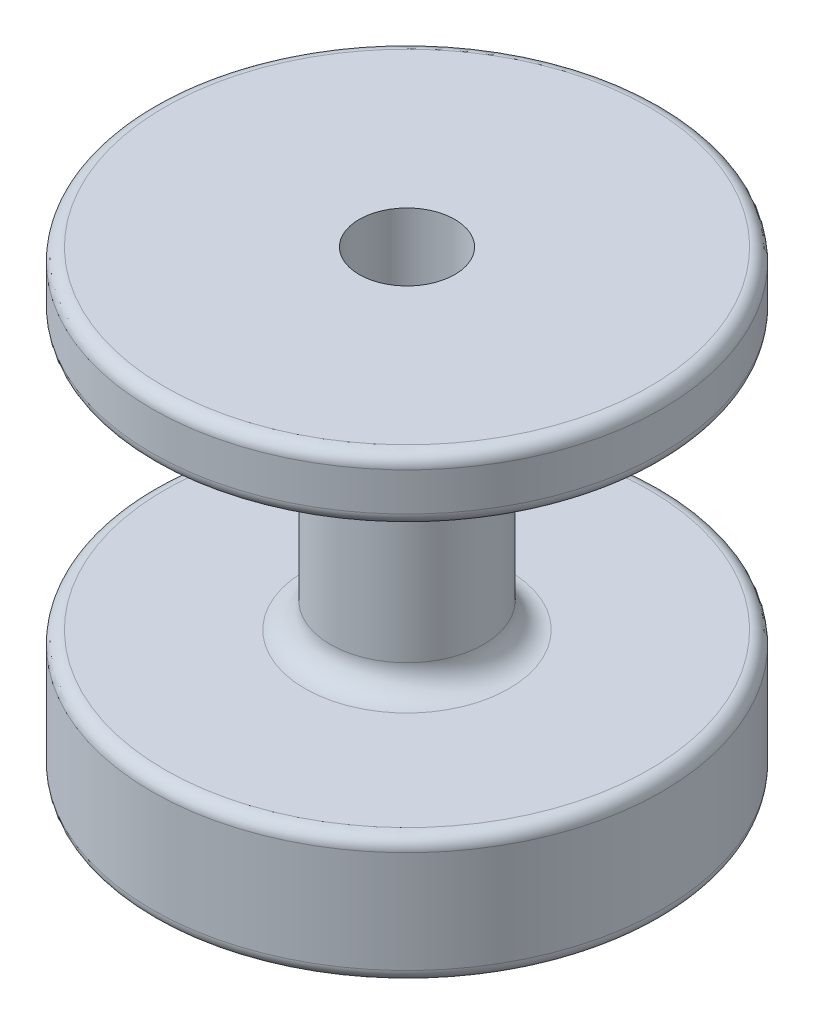
from build123d import *

# Parameters (mm, degrees)
SKETCH_1_R               = 20
EXTRUDE_1_DEPTH          = 36
CUT_EXTRUDE_START        = 10
SKETCH_2_R               = 20
SKETCH_2_R_2             = 6
CUT_EXTRUDE_1_DEPTH      = 21
SKETCH_4_R               = 2
CUT_EXTRUDE_3_DEPTH      = 47
CUT_EXTRUDE_3_DEPTH_BACK = 47
SKETCH_3_R               = 3.75
CUT_EXTRUDE_7_DEPTH      = 17
FILLET_1_R               = 2
FILLET_2_R               = 1


with BuildPart() as part:
    # 草图1 → 凸台-拉伸1 (new body)
    with BuildSketch(Plane(origin=(0, 0, 0), x_dir=(1, 0, 0), z_dir=(0, 1, 0))):
        Circle(SKETCH_1_R)
    extrude(amount=EXTRUDE_1_DEPTH)

    # 草图2 → 切除-拉伸1 (cut)
    with BuildSketch(Plane(origin=(0, 0, 0), x_dir=(1, 0, 0), z_dir=(0, 1, 0)).offset(CUT_EXTRUDE_START)):
        Circle(SKETCH_2_R)
        Circle(SKETCH_2_R_2, mode=Mode.SUBTRACT)
    extrude(amount=CUT_EXTRUDE_1_DEPTH, mode=Mode.SUBTRACT)

    # 草图4 → 切除-拉伸3 (cut, two sides)
    with BuildSketch(Plane(origin=(0, 0, 0), x_dir=(1, 0, 0), z_dir=(0, 1, 0))) as cut_extrude_3_sk:
        Circle(SKETCH_4_R)
    extrude(amount=CUT_EXTRUDE_3_DEPTH, mode=Mode.SUBTRACT)
    extrude(cut_extrude_3_sk.sketch, amount=-CUT_EXTRUDE_3_DEPTH_BACK, mode=Mode.SUBTRACT)

    # 草图3 → 切除-拉伸7 (cut)
    with BuildSketch(Plane(origin=(0, 36, 0), x_dir=(1, 0, 0), z_dir=(0, 1, 0))):
        Circle(SKETCH_3_R)
    extrude(amount=-CUT_EXTRUDE_7_DEPTH, mode=Mode.SUBTRACT)

    # 圆角1
    fillet_1_edges = [part.edges().sort_by_distance(p)[0] for p in [
        (-6, 31, 0),
        (-6, 10, 0),
    ]]
    fillet(fillet_1_edges, radius=FILLET_1_R)

    # 圆角2
    fillet_2_edges = [part.edges().sort_by_distance(p)[0] for p in [
        (-20, 0, 0),
        (-20, 36, 0),
        (-20, 10, 0),
        (-20, 31, 0),
    ]]
    fillet(fillet_2_edges, radius=FILLET_2_R)


solid = part.part
